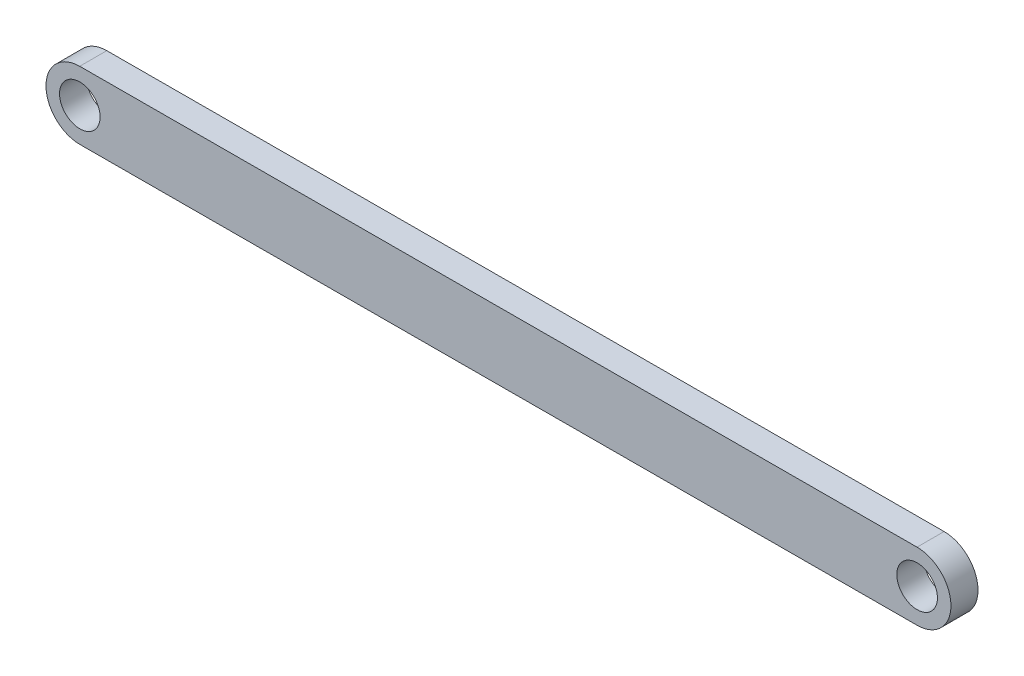
from build123d import *

# Parameters (mm, degrees)
SKETCH1_R           = 1.5
BOSS_EXTRUDE1_DEPTH = 2


with BuildPart() as part:
    # Sketch1 → Boss-Extrude1 (new body)
    with BuildSketch(Plane.XY):
        with BuildLine():
            Line((-31.070055299, 2.327202181), (30.829944701, 2.490824643))
            ThreePointArc((30.829944701, 2.490824643), (33.336544283, -0.002558308), (30.843161332, -2.509157889))
            Line((30.843161332, -2.509157889), (-31.056838668, -2.672780351))
            ThreePointArc((-31.056838668, -2.672780351), (-33.563438249, -0.1793974), (-31.070055299, 2.327202181))
        make_face()
        with Locations((-31.063446983, -0.172789085)):
            Circle(SKETCH1_R, mode=Mode.SUBTRACT)
        with Locations((30.836553017, -0.009166623)):
            Circle(SKETCH1_R, mode=Mode.SUBTRACT)
    extrude(amount=BOSS_EXTRUDE1_DEPTH)


solid = part.part
